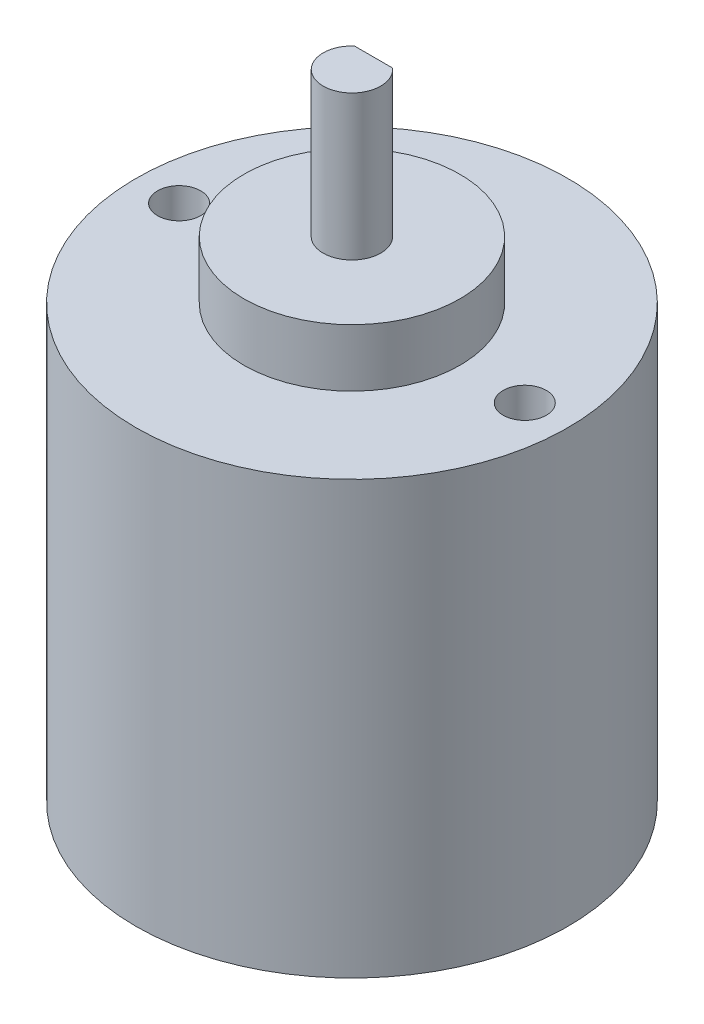
from build123d import *

# Parameters (mm, degrees)
SKETCH1_R           = 15
BOSS_EXTRUDE1_DEPTH = 30
SKETCH4_R           = 1.5
CUT_EXTRUDE1_DEPTH  = 4
SKETCH5_R           = 7.5
BOSS_EXTRUDE2_DEPTH = 4
SKETCH6_R           = 2
BOSS_EXTRUDE3_DEPTH = 2.05
BOSS_EXTRUDE4_DEPTH = 8
SKETCH9_R           = 5
BOSS_EXTRUDE5_DEPTH = 2.5


with BuildPart() as part:
    # Sketch1 → Boss-Extrude1 (new body)
    with BuildSketch(Plane(origin=(0, 0, 0), x_dir=(1, 0, 0), z_dir=(0, 1, 0))):
        Circle(SKETCH1_R)
    extrude(amount=BOSS_EXTRUDE1_DEPTH)

    # Sketch4 → Cut-Extrude1 (cut)
    with BuildSketch(Plane(origin=(0, 30, 0), x_dir=(1, 0, 0), z_dir=(0, 1, 0))):
        with Locations((12.005, 0)):
            Circle(SKETCH4_R)
        with Locations((-12.005, 0)):
            Circle(SKETCH4_R)
    extrude(amount=-CUT_EXTRUDE1_DEPTH, mode=Mode.SUBTRACT)

    # Sketch5 → Boss-Extrude2 (add)
    with BuildSketch(Plane(origin=(0, 30, 0), x_dir=(1, 0, 0), z_dir=(0, 1, 0))):
        Circle(SKETCH5_R)
    extrude(amount=BOSS_EXTRUDE2_DEPTH)

    # Sketch6 → Boss-Extrude3 (add)
    with BuildSketch(Plane(origin=(0, 34, 0), x_dir=(1, 0, 0), z_dir=(0, 1, 0))):
        Circle(SKETCH6_R)
    extrude(amount=BOSS_EXTRUDE3_DEPTH)

    # Sketch7 → Boss-Extrude4 (add)
    with BuildSketch(Plane(origin=(0, 36.05, 0), x_dir=(1, 0, 0), z_dir=(0, 1, 0))):
        with BuildLine():
            Line((-1.322875656, 1.5), (1.322875656, 1.5))
            ThreePointArc((1.322875656, 1.5), (0, -2), (-1.322875656, 1.5))
        make_face()
    extrude(amount=BOSS_EXTRUDE4_DEPTH)

    # Sketch9 → Boss-Extrude5 (add)
    with BuildSketch(Plane.XZ):
        with Locations((0, -8)):
            Circle(SKETCH9_R)
    extrude(amount=BOSS_EXTRUDE5_DEPTH)


solid = part.part
